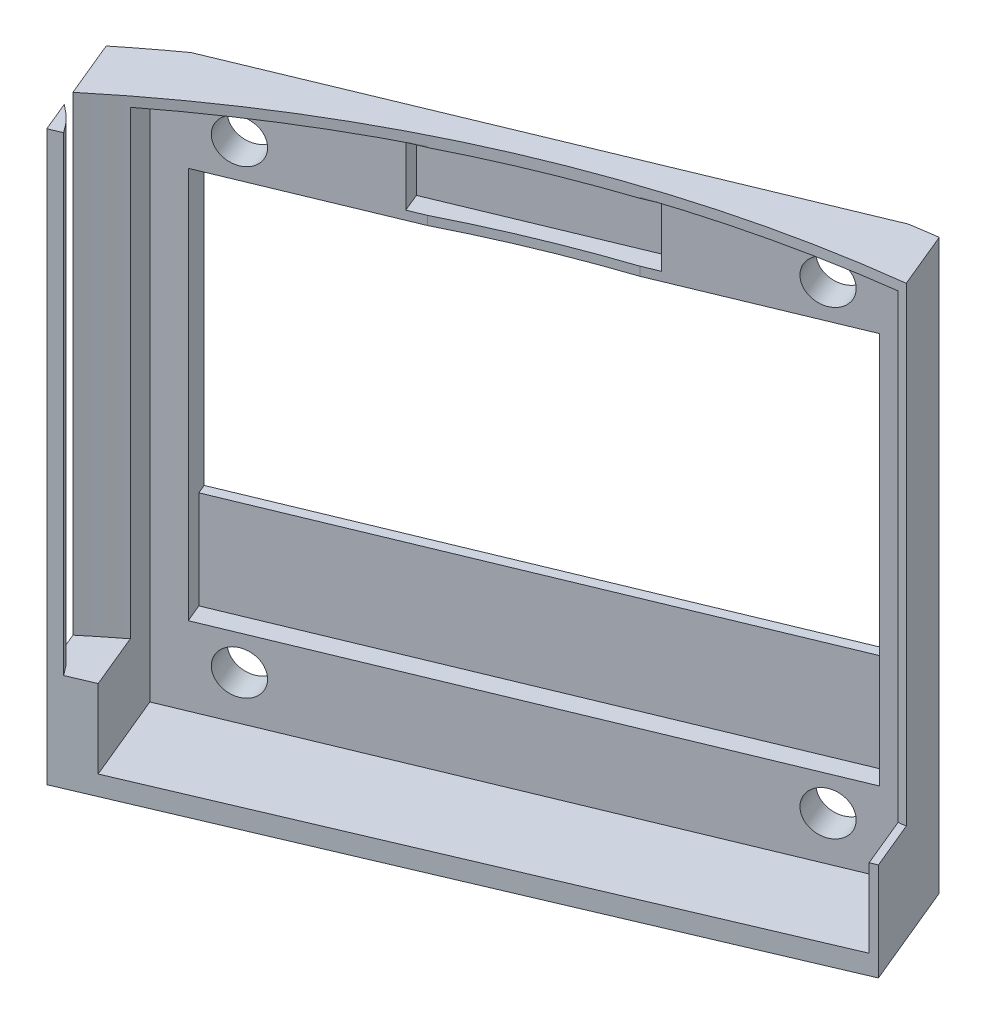
from build123d import *

# Parameters (mm, degrees)
SKETCH1_R                = 60.325
BOSS_EXTRUDE1_DEPTH      = 5
SKETCH3_R                = 60.325
SKETCH3_R_2              = 57.325
BOSS_EXTRUDE3_DEPTH      = 24
BOSS_EXTRUDE13_DEPTH     = 2
SKETCH7_R                = 5.5
CUT_EXTRUDE1_DEPTH       = 5
SKETCH14_R               = 2.5000000000000004
CUT_EXTRUDE7_DEPTH       = 5
SKETCH15_R               = 12.5
BOSS_EXTRUDE15_DEPTH     = 3
SKETCH16_R               = 10.5
CUT_EXTRUDE9_DEPTH       = 5
SKETCH17_R               = 2.5000000000000018
SKETCH17_R_2             = 2.500000000000002
SKETCH17_R_3             = 2.5000000000000004
CUT_EXTRUDE10_DEPTH      = 5
SKETCH20_W               = 10.617189631650703
SKETCH20_H               = 4.842928603910877
CUT_EXTRUDE13_DEPTH      = 1
SKETCH26_W               = 50
SKETCH26_H               = 24
BOSS_EXTRUDE46_DEPTH     = 10
SKETCH27_W               = 45
SKETCH27_H               = 20.000000000000004
CUT_EXTRUDE15_DEPTH      = 5
SKETCH29_R               = 1.0999999999999992
CUT_EXTRUDE17_DEPTH      = 10
CUT_EXTRUDE18_DEPTH      = 20
BOSS_EXTRUDE47_DEPTH     = 24
CUT_EXTRUDE19_START      = -30
CUT_EXTRUDE19_DEPTH      = 30
SKETCH31_R               = 3.0000000000000018
SKETCH31_R_2             = 3.0000000000000004
BOSS_EXTRUDE48_DEPTH     = 10
SKETCH32_R               = 1.5000000000000024
SKETCH32_R_2             = 1.5000000000000042
CUT_EXTRUDE20_DEPTH      = 5
SKETCH33_R               = 2.500000000000004
SKETCH33_R_2             = 2.4999999999999973
BOSS_EXTRUDE49_DEPTH     = 5
SKETCH34_R               = 1.100000000000003
SKETCH34_R_2             = 1.100000000000001
SKETCH34_R_3             = 1.1
SKETCH34_R_4             = 1.0999999999999983
CUT_EXTRUDE21_DEPTH      = 5
BOSS_EXTRUDE50_DEPTH     = 15
BOSS_EXTRUDE51_DEPTH     = 2
CUT_EXTRUDE25_DEPTH      = 2
CUT_EXTRUDE26_DEPTH      = 12
SKETCH41_R               = 1.0999999999999992
SKETCH41_R_2             = 1.100000000000001
CUT_EXTRUDE27_DEPTH      = 12
CUT_EXTRUDE28_DEPTH      = 4
CUT_EXTRUDE28_DEPTH_BACK = 2.5
SKETCH44_R               = 2.499999999999999
BOSS_EXTRUDE52_DEPTH     = 5
SKETCH45_R               = 1.0999999999999983
CUT_EXTRUDE29_DEPTH      = 5
CUT_EXTRUDE30_DEPTH      = 5
SKETCH47_R               = 1.100000000000001
CUT_EXTRUDE31_DEPTH      = 3
CUT_EXTRUDE32_DEPTH      = 5
SKETCH49_W               = 27
SKETCH49_H               = 5
CUT_EXTRUDE33_DEPTH      = 1
SKETCH50_W               = 54.2861765056904
SKETCH50_H               = 77.14351398178086
CUT_EXTRUDE34_DEPTH      = 121.99999999999999
CUT_EXTRUDE35_DEPTH      = 121.99999999999999
CUT_EXTRUDE35_DEPTH_BACK = 121.99999999999999


with BuildPart() as part:
    # Sketch1 → Boss-Extrude1 (new body)
    with BuildSketch(Plane(origin=(0, 0, 0), x_dir=(1, 0, 0), z_dir=(0, 1, 0))):
        Circle(SKETCH1_R)
    extrude(amount=BOSS_EXTRUDE1_DEPTH)

    # Sketch3 → Boss-Extrude3 (add)
    with BuildSketch(Plane(origin=(0, 5, 0), x_dir=(1, 0, 0), z_dir=(0, 1, 0))):
        Circle(SKETCH3_R)
        Circle(SKETCH3_R_2, mode=Mode.SUBTRACT)
    extrude(amount=BOSS_EXTRUDE3_DEPTH)

    # Sketch6 → Boss-Extrude13 (add)
    with BuildSketch(Plane.XY.offset(60.325)):
        Polygon((-7.5, 19.5), (7.5, 19.5), (7.5000000000000036, 4.500000000000001), (-7.4999999999999964, 4.500000000000001), align=None)
    extrude(amount=-BOSS_EXTRUDE13_DEPTH)

    # Sketch7 → Cut-Extrude1 (cut)
    with BuildSketch(Plane.XY.offset(60.325)):
        with Locations((0, 12.313384582393407)):
            Circle(SKETCH7_R)
    extrude(amount=-CUT_EXTRUDE1_DEPTH, mode=Mode.SUBTRACT)

    # Sketch14 → Cut-Extrude7 (cut)
    with BuildSketch(Plane(origin=(0, 0, -60.325), x_dir=(-1, 0, 0), z_dir=(0, 0, -1))):
        with Locations((0, 13.215899789160813)):
            Circle(SKETCH14_R)
    extrude(amount=-CUT_EXTRUDE7_DEPTH, mode=Mode.SUBTRACT)

    # Sketch15 → Boss-Extrude15 (add)
    with BuildSketch(Plane.ZY.offset(60.325)):
        with Locations((0, 14.079498945802262)):
            Circle(SKETCH15_R)
    extrude(amount=-BOSS_EXTRUDE15_DEPTH)

    # Sketch16 → Cut-Extrude9 (cut)
    with BuildSketch(Plane.ZY.offset(60.325)):
        with Locations((0, 14.367365331349822)):
            Circle(SKETCH16_R)
    extrude(amount=-CUT_EXTRUDE9_DEPTH, mode=Mode.SUBTRACT)

    # Sketch17 → Cut-Extrude10 (cut)
    with BuildSketch(Plane(origin=(0, 5, 0), x_dir=(1, 0, 0), z_dir=(0, 1, 0))):
        with Locations((0, 40)):
            Circle(SKETCH17_R)
        with Locations((40, 0)):
            Circle(SKETCH17_R_2)
        with Locations((0, -40)):
            Circle(SKETCH17_R_3)
        with Locations((-40, 0)):
            Circle(SKETCH17_R_2)
    extrude(amount=-CUT_EXTRUDE10_DEPTH, mode=Mode.SUBTRACT)

    # Sketch20 → Cut-Extrude13 (cut)
    with BuildSketch(Plane(origin=(0, 5, 0), x_dir=(1, 0, 0), z_dir=(0, 1, 0))):
        with Locations((0.20330529432061706, 46.91179778863133)):
            Rectangle(SKETCH20_W, SKETCH20_H)
    extrude(amount=-CUT_EXTRUDE13_DEPTH, mode=Mode.SUBTRACT)

    # Sketch26 → Boss-Extrude46 (add)
    with BuildSketch(Plane(origin=(50, 0, 0), x_dir=(0, 0, -1), z_dir=(1, 0, 0))):
        with Locations((3.55e-15, 17.000000000000004)):
            Rectangle(SKETCH26_W, SKETCH26_H)
    extrude(amount=BOSS_EXTRUDE46_DEPTH)

    # Sketch27 → Cut-Extrude15 (cut)
    with BuildSketch(Plane(origin=(60.325, 0, 0), x_dir=(0, 0, -1), z_dir=(1, 0, 0))):
        with Locations((7.11e-15, 15.000000000000002)):
            Rectangle(SKETCH27_W, SKETCH27_H)
    extrude(amount=-CUT_EXTRUDE15_DEPTH, mode=Mode.SUBTRACT)

    # Sketch29 → Cut-Extrude17 (cut)
    with BuildSketch(Plane(origin=(55.325, 0, 0), x_dir=(0, 0, -1), z_dir=(1, 0, 0))):
        with Locations((-19.999999999999986, 20.999999999999996)):
            Circle(SKETCH29_R)
        with Locations((-19.999999999999986, 9)):
            Circle(SKETCH29_R)
        with Locations((20.000000000000018, 20.999999999999996)):
            Circle(SKETCH29_R)
        with Locations((20.000000000000014, 9.151874819132662)):
            Circle(SKETCH29_R)
    extrude(amount=-CUT_EXTRUDE17_DEPTH, mode=Mode.SUBTRACT)

    # Sketch28 → Cut-Extrude18 (cut)
    with BuildSketch(Plane(origin=(60.325, 0, 0), x_dir=(0, 0, -1), z_dir=(1, 0, 0))):
        Polygon((-17.499999999999996, 23.348125180867335), (17.500000000000004, 23.348125180867342), (17.500000000000007, 6.6518748191326615), (-17.499999999999996, 6.651874819132655), align=None)
    extrude(amount=-CUT_EXTRUDE18_DEPTH, mode=Mode.SUBTRACT)

    # Sketch5 → Boss-Extrude47 (add)
    with BuildSketch(Plane(origin=(0, 5, 0), x_dir=(1, 0, 0), z_dir=(0, 1, 0))):
        with BuildLine():
            ThreePointArc((-43.739295545453594, 37.05441471926724), (-35.70889244992055, 35.708892449920754), (-37.054414719267506, 43.73929554545372))
            ThreePointArc((-37.05441471926745, 43.73929554545359), (-38.52084651181077, 42.453504084039004), (-39.94269093151786, 41.118573250408886))
            ThreePointArc((-39.94269093151788, 41.11857325040891), (-37.83021279348029, 37.83021279348028), (-41.1185732504089, 39.942690931517895))
            ThreePointArc((-41.11857325040886, 39.94269093151788), (-42.45350408403905, 38.520846511810724), (-43.739295545453714, 37.0544147192673))
        make_face()
        with BuildLine():
            ThreePointArc((37.05441471926732, 43.73929554545373), (35.70889244992064, 35.70889244992067), (43.739295545453665, 37.05441471926758))
            ThreePointArc((43.73929554545353, 37.05441471926752), (42.45350408403893, 38.52084651181085), (41.11857325040883, 39.94269093151792))
            ThreePointArc((41.11857325040885, 39.94269093151794), (37.83021279348023, 37.830212793480364), (39.94269093151782, 41.11857325040898))
            ThreePointArc((39.942690931517795, 41.11857325040895), (38.52084651181068, 42.45350408403908), (37.05441471926731, 43.739295545453714))
        make_face()
        with BuildLine():
            ThreePointArc((-43.73929554545361, -37.05441471926742), (-42.45350408403899, -38.52084651181079), (-41.11857325040885, -39.94269093151789))
            ThreePointArc((-41.118573250408886, -39.94269093151791), (-37.83021279348029, -37.83021279348027), (-39.94269093151786, -41.11857325040891))
            ThreePointArc((-39.94269093151787, -41.11857325040888), (-38.520846511810724, -42.45350408403905), (-37.05441471926732, -43.7392955454537))
            ThreePointArc((-37.05441471926724, -43.73929554545361), (-35.70889244992073, -35.70889244992055), (-43.739295545453714, -37.05441471926749))
        make_face()
        with BuildLine():
            ThreePointArc((43.73929554545405, -37.0544147192667), (35.70889244992104, -35.70889244992027), (37.054414719267896, -43.7392955454532))
            ThreePointArc((37.05441471926789, -43.73929554545322), (38.52084651181126, -42.45350408403856), (39.94269093151833, -41.11857325040843))
            ThreePointArc((39.94269093151833, -41.11857325040844), (37.83021279348074, -37.83021279347984), (41.118573250409426, -39.942690931517305))
            ThreePointArc((41.118573250409405, -39.942690931517326), (42.453504084039544, -38.520846511810184), (43.739295545454155, -37.05441471926678))
        make_face()
    extrude(amount=BOSS_EXTRUDE47_DEPTH)

    # Sketch30 → Cut-Extrude19 (cut)
    with BuildSketch(Plane(origin=(0, 29, 0), x_dir=(1, 0, 0), z_dir=(0, 1, 0)).offset(CUT_EXTRUDE19_START)):
        with BuildLine():
            Line((51.783140736674326, 30.9453059517236), (68.40972028142612, 30.9453059517236))
            ThreePointArc((68.40972028142612, 30.9453059517236), (75.07900376332695, -0.803108545018857), (67.73210824333012, -32.401594132736065))
            Line((67.73210824333012, -32.401594132736065), (50.88459808878757, -32.401594132736065))
            ThreePointArc((50.88459808878757, -32.401594132736065), (60.31893223906523, -0.8555925075975032), (51.783140736674326, 30.9453059517236))
        make_face()
    extrude(amount=CUT_EXTRUDE19_DEPTH, mode=Mode.SUBTRACT)

    # Sketch31 → Boss-Extrude48 (add)
    with BuildSketch(Plane(origin=(0, 5, 0), x_dir=(1, 0, 0), z_dir=(0, 1, 0))):
        with Locations((-33.05, 28)):
            Circle(SKETCH31_R)
        with Locations((-14.000000000000004, 28)):
            Circle(SKETCH31_R_2)
        with Locations((-13.999999999999996, -27.88)):
            Circle(SKETCH31_R_2)
        with Locations((-33.05, -27.88)):
            Circle(SKETCH31_R)
    extrude(amount=BOSS_EXTRUDE48_DEPTH)

    # Sketch32 → Cut-Extrude20 (cut)
    with BuildSketch(Plane(origin=(0, 15, 0), x_dir=(1, 0, 0), z_dir=(0, 1, 0))):
        with Locations((-13.999999999999996, -27.88)):
            Circle(SKETCH32_R)
        with Locations((-33.05, -27.88)):
            Circle(SKETCH32_R_2)
        with Locations((-33.05, 28)):
            Circle(SKETCH32_R_2)
        with Locations((-14.000000000000004, 28)):
            Circle(SKETCH32_R)
    extrude(amount=-CUT_EXTRUDE20_DEPTH, mode=Mode.SUBTRACT)

    # Sketch33 → Boss-Extrude49 (add)
    with BuildSketch(Plane(origin=(0, 5, 0), x_dir=(1, 0, 0), z_dir=(0, 1, 0))):
        with Locations((-5.000000000000004, 35)):
            Circle(SKETCH33_R)
        with Locations((6.3999989036082425, 35.004999773071894)):
            Circle(SKETCH33_R_2)
        Polygon((-6.750000000000009, -14.647089988643435), (-3.2500000000000084, -14.647089988643431), (-3.2500000000000084, -9.352910011356565), (-6.750000000000009, -9.352910011356565), align=None)
        Polygon((4.649999999999994, -14.647089988643435), (8.149999999999995, -14.647089988643435), (8.149999999999993, -9.352910011356565), (4.649999999999994, -9.352910011356565), align=None)
    extrude(amount=BOSS_EXTRUDE49_DEPTH)

    # Sketch34 → Cut-Extrude21 (cut)
    with BuildSketch(Plane(origin=(0, 10, 0), x_dir=(1, 0, 0), z_dir=(0, 1, 0))):
        with Locations((6.3999989036082425, 35.004999773071894)):
            Circle(SKETCH34_R)
        with Locations((6.399998903608244, -12)):
            Circle(SKETCH34_R_2)
        with Locations((-5.000000000000003, -12)):
            Circle(SKETCH34_R_3)
        with Locations((-5.000000000000004, 35)):
            Circle(SKETCH34_R_4)
    extrude(amount=-CUT_EXTRUDE21_DEPTH, mode=Mode.SUBTRACT)

    # Sketch35 → Boss-Extrude50 (add)
    with BuildSketch(Plane(origin=(0, 5, 0), x_dir=(1, 0, 0), z_dir=(0, 1, 0))):
        Polygon((13.999999999999998, 20), (16.999999999999996, 20), (17, -20), (14.000000000000004, -20), align=None)
    extrude(amount=BOSS_EXTRUDE50_DEPTH)

    # Sketch39 → Boss-Extrude51 (add)
    with BuildSketch(Plane(origin=(21.171960895598467, 0, 51.113635136187), x_dir=(0, -1, 0), z_dir=(0.38268343236508734, 0, 0.9238795325112877))):
        Polygon((-29, 15.014391088551141), (-5.000000000000002, 15.014391088551141), (-4.999999999999997, -14.985608911448859), (-29, -14.985608911448859), align=None)
    boss_extrude51 = extrude(amount=BOSS_EXTRUDE51_DEPTH)

    # Sketch37 → Cut-Extrude25 (cut)
    with BuildSketch(Plane(origin=(23.0853780574239, 0, 55.73303279874344), x_dir=(0, -1, 0), z_dir=(0.38268343236508734, 0, 0.9238795325112877))):
        Polygon((-25, 13.999999999999996), (-5.000000000000001, 13.999999999999996), (-4.999999999999999, -14.000000000000004), (-24.999999999999996, -14.000000000000004), align=None)
    cut_extrude25 = extrude(amount=-CUT_EXTRUDE25_DEPTH, mode=Mode.SUBTRACT)

    # Sketch40 → Cut-Extrude26 (cut)
    with BuildSketch(Plane(origin=(23.0853780574239, 0, 55.73303279874344), x_dir=(0, -1, 0), z_dir=(0.38268343236508734, 0, 0.9238795325112877))):
        Polygon((-23, 9.999999999999996), (-7.000000000000003, 9.999999999999996), (-6.999999999999998, -10.000000000000004), (-22.999999999999996, -10.000000000000004), align=None)
    cut_extrude26 = extrude(amount=-CUT_EXTRUDE26_DEPTH, mode=Mode.SUBTRACT)

    # Sketch41 → Cut-Extrude27 (cut)
    with BuildSketch(Plane(origin=(23.0853780574239, 0, 55.73303279874344), x_dir=(0, -1, 0), z_dir=(0.38268343236508734, 0, 0.9238795325112877))):
        with Locations((-21, 12)):
            Circle(SKETCH41_R)
        with Locations((-9.000000000000002, 12)):
            Circle(SKETCH41_R_2)
        with Locations((-8.999999999999998, -12)):
            Circle(SKETCH41_R_2)
        with Locations((-20.999999999999996, -12)):
            Circle(SKETCH41_R)
    cut_extrude27 = extrude(amount=-CUT_EXTRUDE27_DEPTH, mode=Mode.SUBTRACT)

    # Mirror2: Boss-Extrude51, Cut-Extrude25, Cut-Extrude26, Cut-Extrude27 across plane
    add(boss_extrude51.mirror(Plane(origin=(0, 0, 0), x_dir=(0, 0, 1), z_dir=(1, 0, 0))))
    add(cut_extrude25.mirror(Plane(origin=(0, 0, 0), x_dir=(0, 0, 1), z_dir=(1, 0, 0))), mode=Mode.SUBTRACT)
    add(cut_extrude26.mirror(Plane(origin=(0, 0, 0), x_dir=(0, 0, 1), z_dir=(1, 0, 0))), mode=Mode.SUBTRACT)
    add(cut_extrude27.mirror(Plane(origin=(0, 0, 0), x_dir=(0, 0, 1), z_dir=(1, 0, 0))), mode=Mode.SUBTRACT)

    # Sketch43 → Cut-Extrude28 (cut, two sides: drawn at the far end of the back side and taken through both)
    with BuildSketch(Plane(origin=(-20.923216664561146, 0, -50.51311344005465), x_dir=(0, -1, 0), z_dir=(0.38268343236508734, 0, 0.9238795325112877)).offset(-CUT_EXTRUDE28_DEPTH_BACK)):
        Polygon((-28.5, 15), (-1.0000000000000009, 15), (-0.9999999999999974, -15), (-28.499999999999996, -15), align=None)
    extrude(amount=CUT_EXTRUDE28_DEPTH + CUT_EXTRUDE28_DEPTH_BACK, mode=Mode.SUBTRACT)

    # Sketch44 → Boss-Extrude52 (add)
    with BuildSketch(Plane(origin=(0, 5, 0), x_dir=(1, 0, 0), z_dir=(0, 1, 0))):
        with Locations((-20, 45)):
            Circle(SKETCH44_R)
        with Locations((18.229539652623778, 45)):
            Circle(SKETCH44_R)
        with Locations((18.229539652623778, -32.02717202587299)):
            Circle(SKETCH44_R)
    extrude(amount=BOSS_EXTRUDE52_DEPTH)

    # Sketch45 → Cut-Extrude29 (cut)
    with BuildSketch(Plane(origin=(0, 10, 0), x_dir=(1, 0, 0), z_dir=(0, 1, 0))):
        with Locations((-20, 45)):
            Circle(SKETCH45_R)
        with Locations((18.229539652623778, 45)):
            Circle(SKETCH45_R)
        with Locations((18.229539652623778, -32.02717202587299)):
            Circle(SKETCH45_R)
    extrude(amount=-CUT_EXTRUDE29_DEPTH, mode=Mode.SUBTRACT)

    # Sketch46 → Cut-Extrude30 (cut)
    with BuildSketch(Plane(origin=(-21.879925245473853, 0, -52.82281227133289), x_dir=(0.9238795325112877, 0, -0.38268343236508756), z_dir=(0.38268343236508756, 0, 0.9238795325112877))):
        Polygon((-13.50000000000003, 25), (13.49999999999997, 25), (13.499999999999968, 10), (-13.500000000000028, 10), align=None)
    extrude(amount=-CUT_EXTRUDE30_DEPTH, mode=Mode.SUBTRACT)

    # Sketch47 → Cut-Extrude31 (cut)
    with BuildSketch(Plane(origin=(-21.879925245473853, 0, -52.82281227133289), x_dir=(0.9238795325112877, 0, -0.38268343236508756), z_dir=(0.38268343236508756, 0, 0.9238795325112877))):
        with Locations((11.500000000000005, 26.75)):
            Circle(SKETCH47_R)
        with Locations((-11.499999999999995, 26.75)):
            Circle(SKETCH47_R)
        with Locations((-11.5, 3.25)):
            Circle(SKETCH47_R)
        with Locations((11.500000000000002, 3.25)):
            Circle(SKETCH47_R)
    extrude(amount=-CUT_EXTRUDE31_DEPTH, mode=Mode.SUBTRACT)

    # Sketch48 → Cut-Extrude32 (cut)
    with BuildSketch(Plane(origin=(-22.453950394021497, 0, -54.208631570099804), x_dir=(0, -1, 0), z_dir=(0.38268343236508734, 0, 0.9238795325112877))):
        Polygon((-35, 15), (4.999999999999997, 15), (5.000000000000004, -15), (-34.99999999999999, -15), align=None)
    extrude(amount=-CUT_EXTRUDE32_DEPTH, mode=Mode.SUBTRACT)

    # Sketch49 → Cut-Extrude33 (cut)
    with BuildSketch(Plane(origin=(-21.87992524547385, 0, -52.82281227133288), x_dir=(0.9238795325112878, 0, -0.3826834323650871), z_dir=(0.3826834323650871, 0, 0.9238795325112878))):
        Polygon((-5.0000000000000036, 28.45000478430176), (4.9999999999999964, 28.45000478430176), (4.999999999999996, 25.45000478430176), (-5.000000000000003, 25.45000478430176), align=None)
        with Locations((-4.44e-15, 7.5)):
            Rectangle(SKETCH49_W, SKETCH49_H)
    extrude(amount=-CUT_EXTRUDE33_DEPTH, mode=Mode.SUBTRACT)

    # Sketch50 → Cut-Extrude34 (cut)
    with BuildSketch(Plane(origin=(-22.453950394021497, 0, -54.208631570099804), x_dir=(0, -1, 0), z_dir=(0.38268343236508734, 0, 0.9238795325112877))):
        with Locations((-17.857252330295086, 53.93404146233521)):
            Rectangle(SKETCH50_W, SKETCH50_H)
        Polygon((-45.000340583140286, -17), (9.28583592255012, -17), (9.28583592255013, -76.71479415626372), (-45.00034058314028, -76.71479415626372), align=None)
    extrude(amount=CUT_EXTRUDE34_DEPTH, mode=Mode.SUBTRACT)

    # Sketch51 → Cut-Extrude35 (cut, two sides: drawn at the far end of the back side and taken through both)
    with BuildSketch(Plane(origin=(0, 5, 0), x_dir=(1, 0, 0), z_dir=(0, 1, 0)).offset(-CUT_EXTRUDE35_DEPTH_BACK)):
        Polygon((-45.373232140480866, 37.67891691481655), (7.973371924553829, 60.4006186462202), (56.61957897539295, -53.8122152992282), (1.6860833467658822, -72.80817162045847), align=None)
    extrude(amount=CUT_EXTRUDE35_DEPTH + CUT_EXTRUDE35_DEPTH_BACK, mode=Mode.SUBTRACT)


solid = part.part
